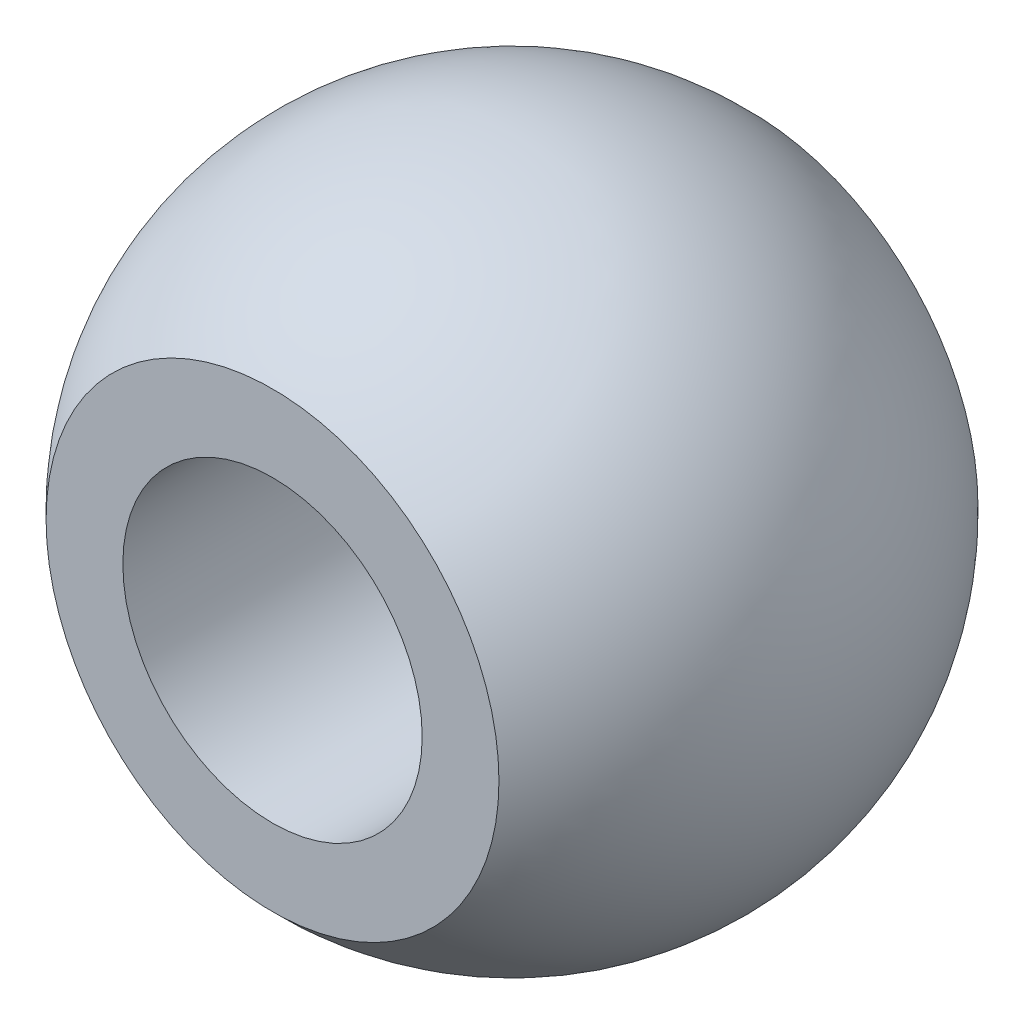
from build123d import *

# Parameters (mm, degrees)
CUT_EXTRUDE1_DEPTH      = 10.534939696
CUT_EXTRUDE1_DEPTH_BACK = 10.534939696
SKETCH2_R               = 2.5
SKETCH3_W               = 16.261433764
SKETCH3_H               = 16.18364637
CUT_EXTRUDE2_DEPTH      = 13.286377619


with BuildPart() as part:
    # Sketch1 → Revolve2 (revolve)
    with BuildSketch(Plane.XY):
        with BuildLine():
            Line((0, 5.505), (0, -5.505))
            ThreePointArc((0, -5.505), (3.89262283, -3.89262283), (5.505, 0))
            ThreePointArc((5.505, 0), (3.89262283, 3.89262283), (0, 5.505))
        make_face()
    revolve(axis=Axis((0, -1000, 0), (0, 1, 0)))

    # Sketch2 → Cut-Extrude1 (cut, two sides: drawn at the far end of the back side and taken through both)
    with BuildSketch(Plane.XY.offset(-CUT_EXTRUDE1_DEPTH_BACK)):
        Circle(SKETCH2_R)
    extrude(amount=CUT_EXTRUDE1_DEPTH + CUT_EXTRUDE1_DEPTH_BACK, mode=Mode.SUBTRACT)

    # Sketch3 → Cut-Extrude2 (cut, through all)
    with BuildSketch(Plane.XY.offset(4)):
        Rectangle(SKETCH3_W, SKETCH3_H)
    cut_extrude2 = extrude(amount=CUT_EXTRUDE2_DEPTH, mode=Mode.SUBTRACT)

    # Mirror1: Cut-Extrude2 across plane
    add(cut_extrude2.mirror(Plane.XY), mode=Mode.SUBTRACT)


solid = part.part
